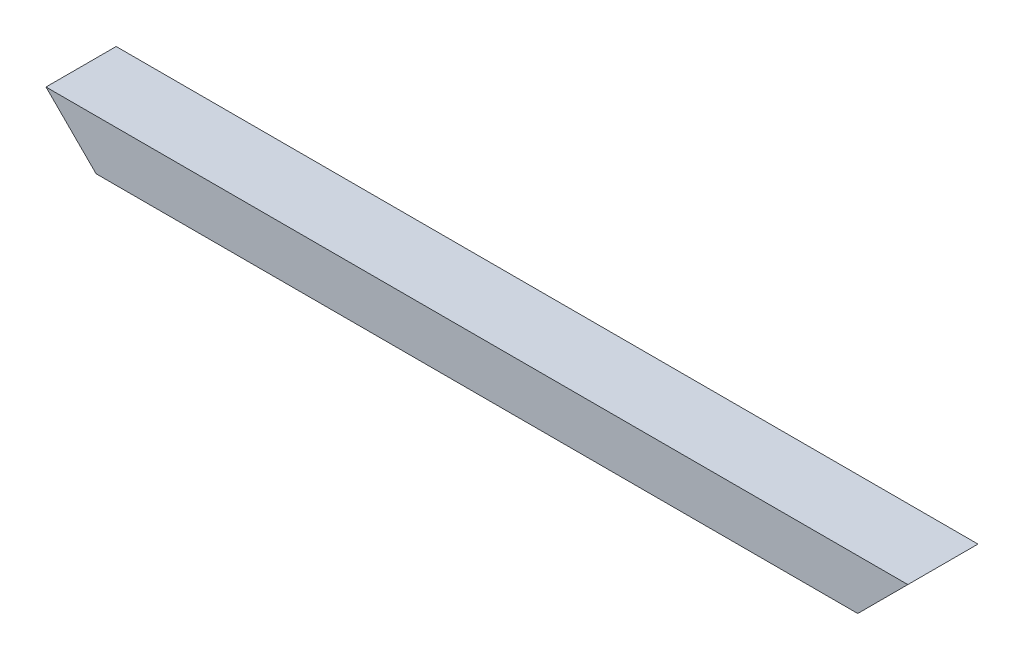
from build123d import *

# Parameters (mm, degrees)
BOSS_EXTRUDE1_DEPTH = 88.9


with BuildPart() as part:
    # Sketch2 → Boss-Extrude1 (new body)
    with BuildSketch(Plane.XY):
        Polygon((0, 0), (965.2, 0), (1028.7, 63.5), (-63.5, 63.5), align=None)
    extrude(amount=BOSS_EXTRUDE1_DEPTH)


solid = part.part
